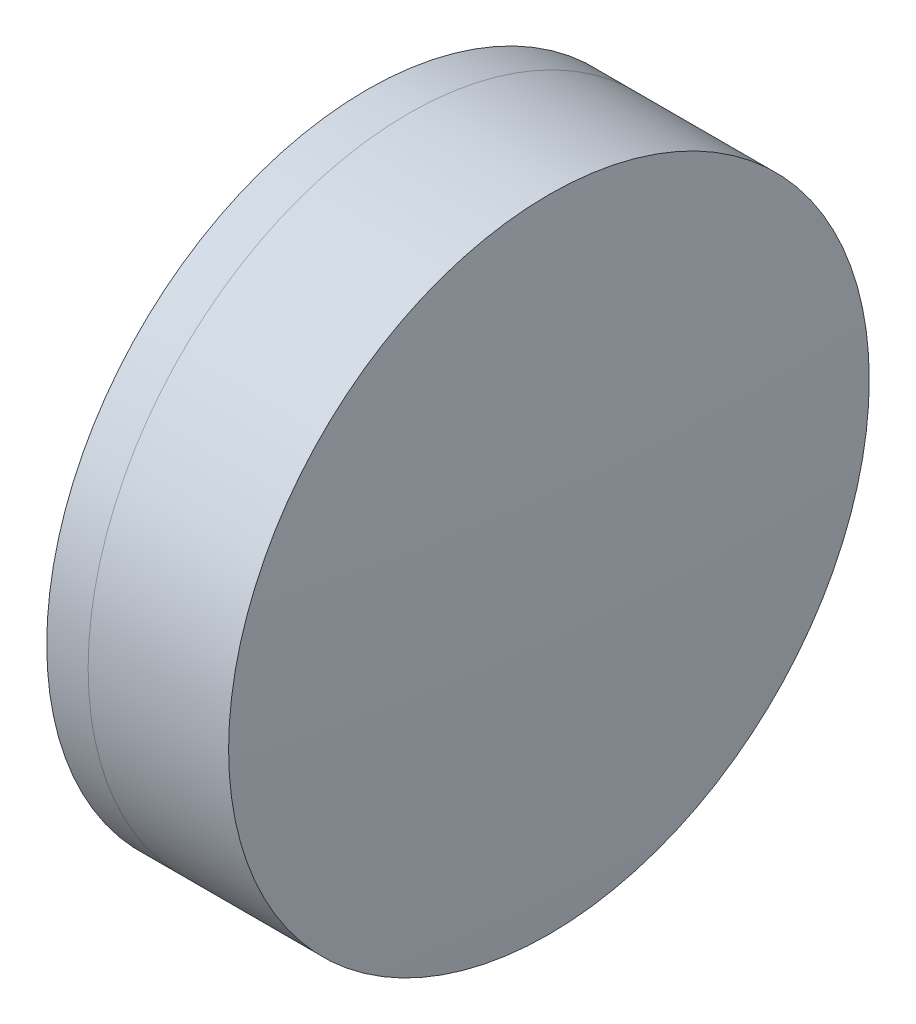
from build123d import *


with BuildPart() as part:
    # 草图1 one side → 旋转1 (revolve)
    with BuildSketch(Plane(origin=(0, 0, 0), x_dir=(1, 0, 0), z_dir=(0, 1, 0)), mode=Mode.PRIVATE) as revolve_1_sk:
        with BuildLine():
            ThreePointArc((302.302709283, 25.4), (298.793702916, 12.91484532), (297.610916607, 0))
            Line((297.610916607, 0), (313.610916607, 0))
            ThreePointArc((313.610916607, 0), (311.556396659, 13.319103242), (305.583834654, 25.4))
            Line((305.583834654, 25.4), (302.302709283, 25.4))
        make_face()
    revolve(revolve_1_sk.sketch.rotate(Axis((124.523309526, 0, 0), (1, 0, 0)), 180), axis=Axis((124.523309526, 0, 0), (1, 0, 0)))  # turned: the seam where the file's is


with BuildPart() as body_2:
    # 草图2 one side → 旋转3 (revolve)
    with BuildSketch(Plane(origin=(0, 0, 0), x_dir=(1, 0, 0), z_dir=(0, 1, 0)), mode=Mode.PRIVATE) as revolve_3_sk:
        with BuildLine():
            Line((316.721421701, 25.4), (305.583834654, 25.4))
            ThreePointArc((305.583834654, 25.4), (311.556396659, 13.319103242), (313.610916607, 0))
            Line((313.610916607, 0), (317.610916607, 0))
            ThreePointArc((317.610916607, 0), (317.388474745, 12.707785027), (316.721421701, 25.4))
        make_face()
    revolve(revolve_3_sk.sketch.rotate(Axis((-0.551919993, 0, 0), (1, 0, 0)), 180), axis=Axis((-0.551919993, 0, 0), (1, 0, 0)))  # turned: the seam where the file's is


solid = Compound([part.part, body_2.part])
